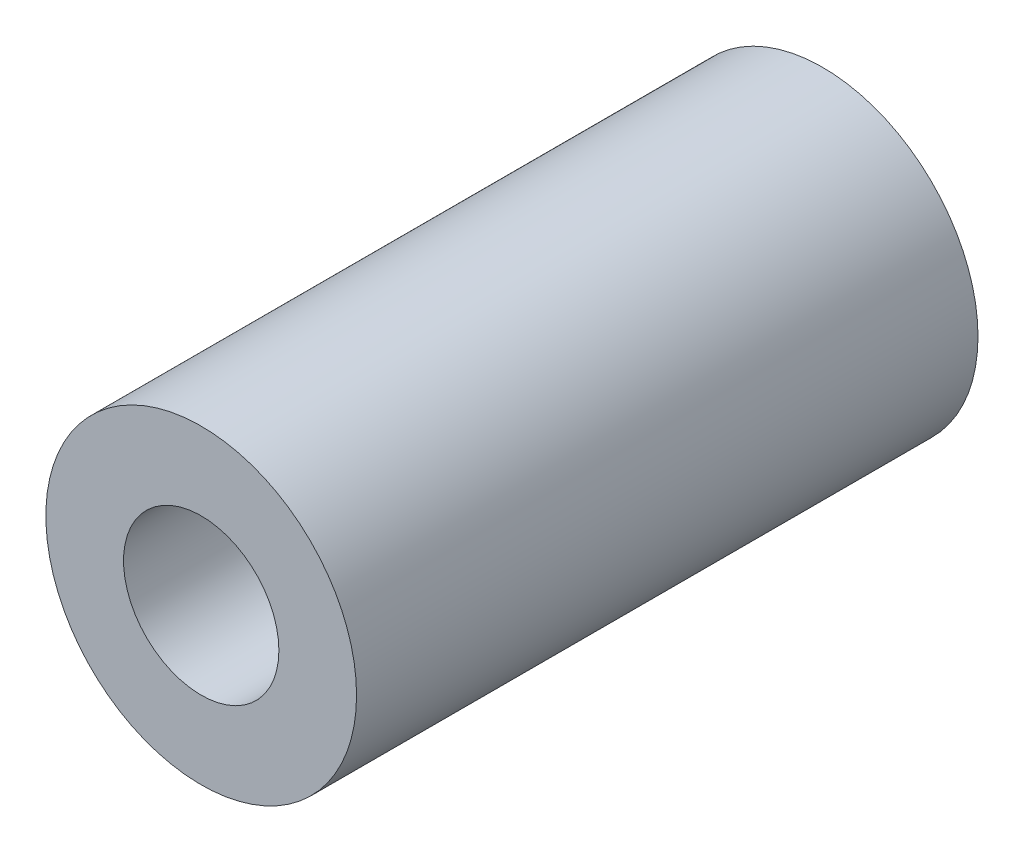
from build123d import *

# Parameters (mm, degrees)
SKETCH2_R           = 10
BOSS_EXTRUDE1_DEPTH = 40
SKETCH3_R           = 5
CUT_EXTRUDE1_DEPTH  = 41


with BuildPart() as part:
    # Sketch2 → Boss-Extrude1 (new body)
    with BuildSketch(Plane.XY):
        Circle(SKETCH2_R)
    extrude(amount=-BOSS_EXTRUDE1_DEPTH)

    # Sketch3 → Cut-Extrude1 (cut, through all)
    with BuildSketch(Plane.XY):
        Circle(SKETCH3_R)
    extrude(amount=-CUT_EXTRUDE1_DEPTH, mode=Mode.SUBTRACT)


solid = part.part
